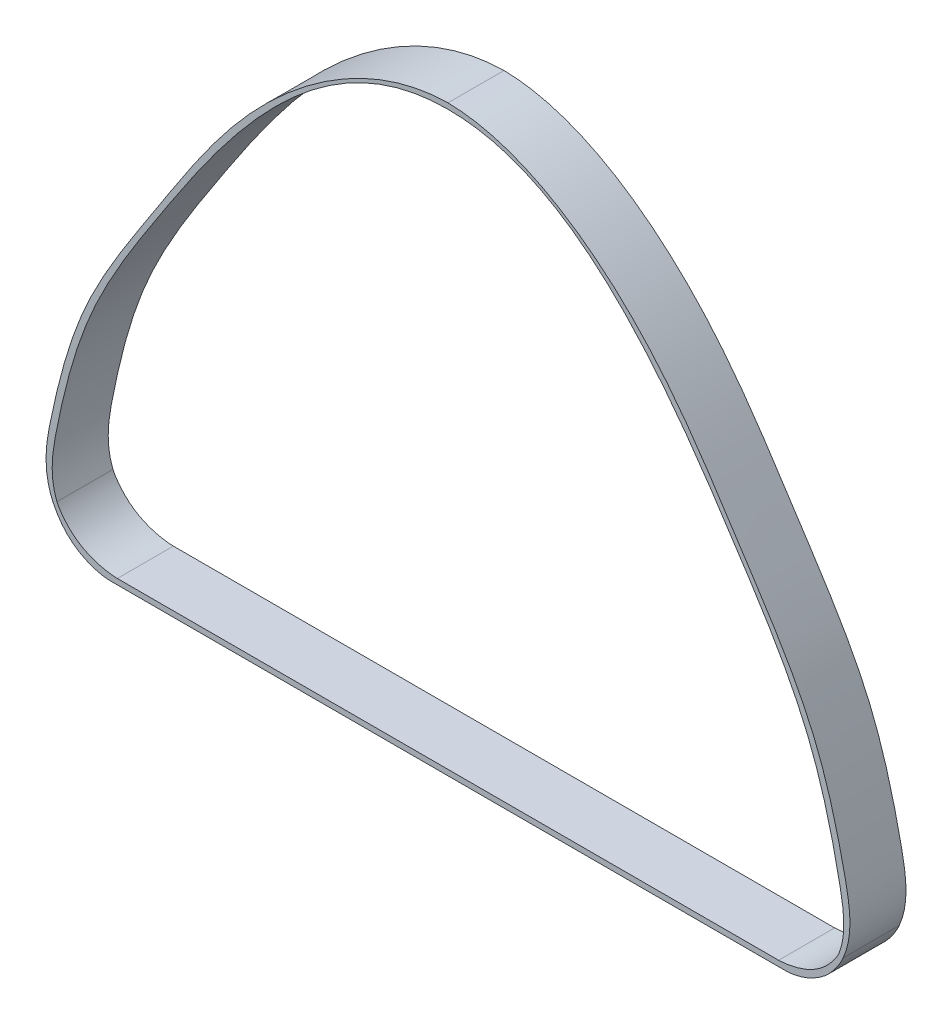
from build123d import *

# Parameters (mm, degrees)
EXTRUDE_1_DEPTH = 5


with BuildPart() as part:
    # 草图1 → 凸台-拉伸1 (new body)
    with BuildSketch(Plane.XY):
        with BuildLine():
            Line((-30, -20), (30, -20))
            add(Edge.make_bspline(
                [(35.258436844, -16.441279115), (34.996443421, -17.020908852), (33.690556146, -19.14256109), (31.185354686, -20.029316023), (30, -20)],
                knots=[0, 0, 0, 0, 0.359900696, 1, 1, 1, 1], degree=3))
            add(Edge.make_bspline(
                [(0, 32), (6.525531342, 31.903595671), (17.503513361, 24.330693276), (25.717632299, 11.137446439), (32.791173162, 0.606888673), (35.263590912, -8.864538837), (36.230061186, -14.212016256), (35.258436844, -16.441279115)],
                knots=[0, 0, 0, 0, 0.310761872, 0.543527622, 0.745406531, 0.898184222, 1, 1, 1, 1], degree=3))
            add(Edge.make_bspline(
                [(0, 32), (-6.525531342, 31.903595671), (-17.503513361, 24.330693276), (-25.717632299, 11.137446439), (-32.791173162, 0.606888673), (-35.263590912, -8.864538837), (-36.230061186, -14.212016256), (-35.258436844, -16.441279115)],
                knots=[0, 0, 0, 0, 0.310761872, 0.543527622, 0.745406531, 0.898184222, 1, 1, 1, 1], degree=3))
            add(Edge.make_bspline(
                [(-35.258436844, -16.441279115), (-34.996443421, -17.020908852), (-33.690556146, -19.14256109), (-31.185354686, -20.029316023), (-30, -20)],
                knots=[0, 0, 0, 0, 0.359900696, 1, 1, 1, 1], degree=3))
        make_face()
        with BuildLine():
            Line((-29.5, -19.5), (29.5, -19.5))
            add(Edge.make_bspline(
                [(34.890127266, -16.269533538), (34.6657296, -16.77811749), (33.075477178, -18.921269545), (30.54880391, -19.479382043), (29.5, -19.5)],
                knots=[0, 0, 0, 0, 0.376949426, 1, 1, 1, 1], degree=3))
            add(Edge.make_bspline(
                [(0, 31.5), (7.255109393, 31.511140377), (16.953333091, 23.715865479), (25.440161273, 10.941999217), (32.281116574, 0.338428353), (34.676893489, -8.991154632), (35.604835183, -14.429114988), (34.890127266, -16.269533538)],
                knots=[0, 0, 0, 0, 0.317686176, 0.539497046, 0.743916362, 0.910983569, 1, 1, 1, 1], degree=3))
            add(Edge.make_bspline(
                [(0, 31.5), (-7.255109393, 31.511140377), (-16.953333091, 23.715865479), (-25.440161273, 10.941999217), (-32.281116574, 0.338428353), (-34.676893489, -8.991154632), (-35.604835183, -14.429114988), (-34.890127266, -16.269533538)],
                knots=[0, 0, 0, 0, 0.317686176, 0.539497046, 0.743916362, 0.910983569, 1, 1, 1, 1], degree=3))
            add(Edge.make_bspline(
                [(-34.890127266, -16.269533538), (-34.6657296, -16.77811749), (-33.075477178, -18.921269545), (-30.54880391, -19.479382043), (-29.5, -19.5)],
                knots=[0, 0, 0, 0, 0.376949426, 1, 1, 1, 1], degree=3))
        make_face(mode=Mode.SUBTRACT)
    extrude(amount=EXTRUDE_1_DEPTH)


solid = part.part
